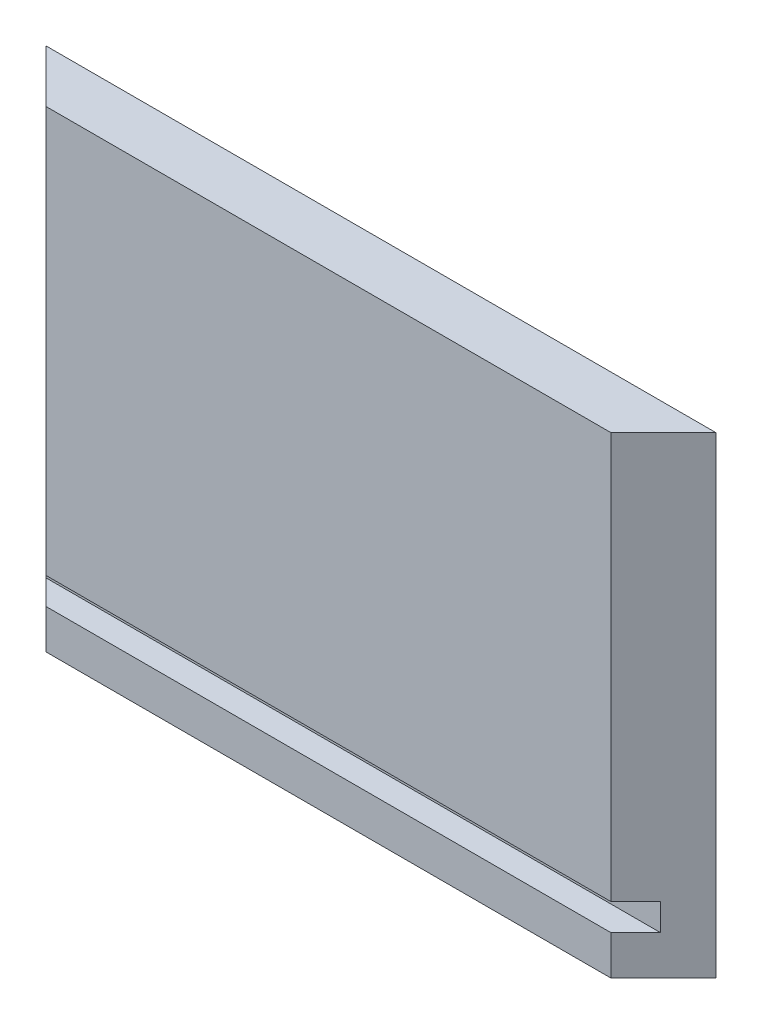
from build123d import *

# Parameters (mm, degrees)
BOSS_EXTRUDE1_DEPTH     = 57.15
SKETCH2_W               = 2.9972
SKETCH2_H               = 3.2512
CUT_EXTRUDE1_DEPTH      = 82.0006
CUT_EXTRUDE1_DEPTH_BACK = 1


with BuildPart() as part:
    # Sketch1 → Boss-Extrude1 (new body)
    with BuildSketch(Plane(origin=(0, 0, 0), x_dir=(1, 0, 0), z_dir=(0, 1, 0))):
        Polygon((0, 0), (81.0006, 0), (74.6506, -6.35), (6.35, -6.35), align=None)
    extrude(amount=BOSS_EXTRUDE1_DEPTH)

    # Sketch2 → Cut-Extrude1 (cut, two sides)
    with BuildSketch(Plane(origin=(0, 0, 0), x_dir=(0, 0, -1), z_dir=(1, 0, 0))) as cut_extrude1_sk:
        with Locations((-4.8514, 6.3881)):
            Rectangle(SKETCH2_W, SKETCH2_H)
    extrude(amount=CUT_EXTRUDE1_DEPTH, mode=Mode.SUBTRACT)
    extrude(cut_extrude1_sk.sketch, amount=-CUT_EXTRUDE1_DEPTH_BACK, mode=Mode.SUBTRACT)


solid = part.part
